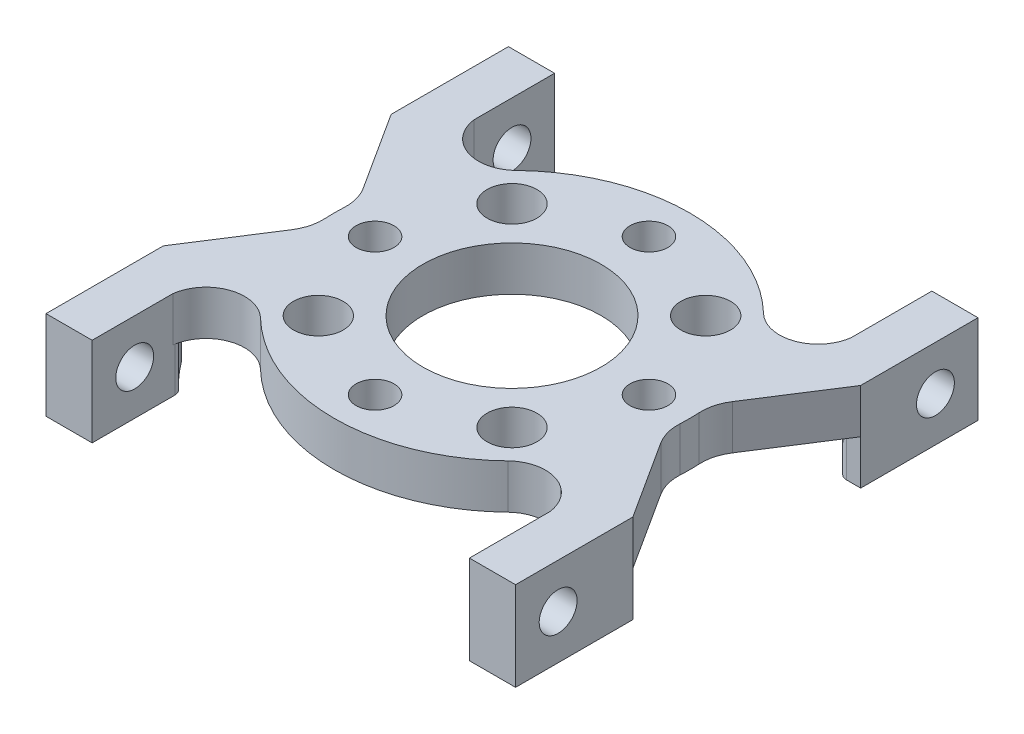
from build123d import *

# Parameters (mm, degrees)
SKETCH1_W                  = 33.528
SKETCH1_H                  = 33.02
BOSS_EXTRUDE1_DEPTH        = 3.175
CUT_EXTRUDE1_DEPTH         = 4.175
SKETCH3_W                  = 3.29438
SKETCH3_H                  = 8.37692
BOSS_EXTRUDE2_DEPTH        = 3.175
CUT_EXTRUDE2_DEPTH         = 7.35
SKETCH5_W                  = 3.29438
SKETCH5_H                  = 8.37692
BOSS_EXTRUDE3_DEPTH        = 3.175
CUT_EXTRUDE3_DEPTH         = 7.35
SKETCH7_W                  = 3.29438
SKETCH7_H                  = 8.37692
BOSS_EXTRUDE4_DEPTH        = 3.175
CUT_EXTRUDE4_DEPTH         = 7.35
SKETCH9_W                  = 3.29438
SKETCH9_H                  = 8.37692
BOSS_EXTRUDE5_DEPTH        = 3.175
CUT_EXTRUDE5_DEPTH         = 3.175
CUT_EXTRUDE6_DEPTH         = 3.175
CUT_EXTRUDE7_DEPTH         = 3.175
CUT_EXTRUDE8_DEPTH         = 3.175
HOLE1_D                    = 12.7254
HOLE1_DEPTH                = 3.175025
M2_5_CLEARANCE_HOLE1_D     = 2.7051
M2_5_CLEARANCE_HOLE1_DEPTH = 3.175025
M3_CLEARANCE_HOLE1_D       = 3.556
M3_CLEARANCE_HOLE1_DEPTH   = 3.175025
M2_5_CLEARANCE_HOLE2_D     = 2.7051
M2_5_CLEARANCE_HOLE2_DEPTH = 3.29438
M2_5_CLEARANCE_HOLE3_D     = 2.7051
M2_5_CLEARANCE_HOLE3_DEPTH = 3.29438
M2_5_CLEARANCE_HOLE4_D     = 2.7051
M2_5_CLEARANCE_HOLE4_DEPTH = 3.29443
FILLET1_R                  = 0.635
FILLET2_R                  = 3.175


with BuildPart() as part:
    # Sketch1 → Boss-Extrude1 (new body)
    with BuildSketch(Plane.XZ):
        Rectangle(SKETCH1_W, SKETCH1_H)
    extrude(amount=-BOSS_EXTRUDE1_DEPTH)

    # Sketch2 → Cut-Extrude1 (cut, through all)
    with BuildSketch(Plane(origin=(0, 3.175, 0), x_dir=(-1, 0, 0), z_dir=(0, 1, 0))):
        with BuildLine():
            Line((-13.46962, 16.51), (-13.46962, 10.753335779))
            ThreePointArc((-13.46962, 10.753335779), (-11.652039651, 8.508623021), (-8.8307675, 9.127296717))
            ThreePointArc((-8.8307675, 9.127296717), (0, 12.7), (8.8307675, 9.127296717))
            ThreePointArc((8.8307675, 9.127296717), (11.652039651, 8.508623021), (13.46962, 10.753335779))
            Line((13.46962, 10.753335779), (13.46962, 16.51))
            Line((13.46962, 16.51), (-13.46962, 16.51))
        make_face()
    extrude(amount=-CUT_EXTRUDE1_DEPTH, mode=Mode.SUBTRACT)

    # Sketch3 → Boss-Extrude2 (add)
    with BuildSketch(Plane.XZ):
        with Locations((-15.11681, 12.32154)):
            Rectangle(SKETCH3_W, SKETCH3_H)
    extrude(amount=BOSS_EXTRUDE2_DEPTH)

    # Sketch4 → Cut-Extrude2 (cut, through all)
    with BuildSketch(Plane(origin=(0, 3.175, 0), x_dir=(-1, 0, 0), z_dir=(0, 1, 0))):
        with BuildLine():
            Line((-16.764, 8.13308), (-16.764, -8.13308))
            Line((-16.764, -8.13308), (-12.593680427, -1.639882101))
            ThreePointArc((-12.593680427, -1.639882101), (-12.7, 0), (-12.593680427, 1.639882101))
            Line((-12.593680427, 1.639882101), (-16.764, 8.13308))
        make_face()
    extrude(amount=-CUT_EXTRUDE2_DEPTH, mode=Mode.SUBTRACT)

    # Sketch5 → Boss-Extrude3 (add)
    with BuildSketch(Plane.XZ):
        with Locations((15.11681, 12.32154)):
            Rectangle(SKETCH5_W, SKETCH5_H)
    extrude(amount=BOSS_EXTRUDE3_DEPTH)

    # Sketch6 → Cut-Extrude3 (cut, through all)
    with BuildSketch(Plane(origin=(0, 3.175, 0), x_dir=(-1, 0, 0), z_dir=(0, 1, 0))):
        with BuildLine():
            Line((13.46962, -16.51), (13.46962, -10.753335779))
            ThreePointArc((13.46962, -10.753335779), (11.652039651, -8.508623021), (8.8307675, -9.127296717))
            ThreePointArc((8.8307675, -9.127296717), (0, -12.7), (-8.8307675, -9.127296717))
            ThreePointArc((-8.8307675, -9.127296717), (-11.652039651, -8.508623021), (-13.46962, -10.753335779))
            Line((-13.46962, -10.753335779), (-13.46962, -16.51))
            Line((-13.46962, -16.51), (13.46962, -16.51))
        make_face()
    extrude(amount=-CUT_EXTRUDE3_DEPTH, mode=Mode.SUBTRACT)

    # Sketch7 → Boss-Extrude4 (add)
    with BuildSketch(Plane.XZ):
        with Locations((15.11681, -12.32154)):
            Rectangle(SKETCH7_W, SKETCH7_H)
    extrude(amount=BOSS_EXTRUDE4_DEPTH)

    # Sketch8 → Cut-Extrude4 (cut, through all)
    with BuildSketch(Plane(origin=(0, 3.175, 0), x_dir=(-1, 0, 0), z_dir=(0, 1, 0))):
        with BuildLine():
            Line((16.764, -8.13308), (16.764, 8.13308))
            Line((16.764, 8.13308), (12.593680427, 1.639882101))
            ThreePointArc((12.593680427, 1.639882101), (12.7, 0), (12.593680427, -1.639882101))
            Line((12.593680427, -1.639882101), (16.764, -8.13308))
        make_face()
    extrude(amount=-CUT_EXTRUDE4_DEPTH, mode=Mode.SUBTRACT)

    # Sketch9 → Boss-Extrude5 (add)
    with BuildSketch(Plane.XZ):
        with Locations((-15.11681, -12.32154)):
            Rectangle(SKETCH9_W, SKETCH9_H)
    extrude(amount=BOSS_EXTRUDE5_DEPTH)

    # Sketch10 → Cut-Extrude5 (cut)
    with BuildSketch(Plane.XZ.offset(3.175)):
        with BuildLine():
            Line((15.422429016, -8.13308), (13.46962, -8.13308))
            Line((13.46962, -8.13308), (13.46962, -10.329337463))
            ThreePointArc((13.46962, -10.329337463), (14.503938678, -9.282703292), (15.422429016, -8.13308))
        make_face()
    extrude(amount=-CUT_EXTRUDE5_DEPTH, mode=Mode.SUBTRACT)

    # Sketch11 → Cut-Extrude6 (cut)
    with BuildSketch(Plane.XZ.offset(3.175)):
        with BuildLine():
            Line((13.46962, 10.329337463), (13.46962, 8.13308))
            Line((13.46962, 8.13308), (15.422429016, 8.13308))
            ThreePointArc((15.422429016, 8.13308), (14.503938678, 9.282703292), (13.46962, 10.329337463))
        make_face()
    extrude(amount=-CUT_EXTRUDE6_DEPTH, mode=Mode.SUBTRACT)

    # Sketch12 → Cut-Extrude7 (cut)
    with BuildSketch(Plane.XZ.offset(3.175)):
        with BuildLine():
            Line((-15.422429016, 8.13308), (-13.46962, 8.13308))
            Line((-13.46962, 8.13308), (-13.46962, 10.329337463))
            ThreePointArc((-13.46962, 10.329337463), (-14.503938678, 9.282703292), (-15.422429016, 8.13308))
        make_face()
    extrude(amount=-CUT_EXTRUDE7_DEPTH, mode=Mode.SUBTRACT)

    # Sketch13 → Cut-Extrude8 (cut)
    with BuildSketch(Plane.XZ.offset(3.175)):
        with BuildLine():
            Line((-13.46962, -10.329337463), (-13.46962, -8.13308))
            Line((-13.46962, -8.13308), (-15.422429016, -8.13308))
            ThreePointArc((-15.422429016, -8.13308), (-14.503938678, -9.282703292), (-13.46962, -10.329337463))
        make_face()
    extrude(amount=-CUT_EXTRUDE8_DEPTH, mode=Mode.SUBTRACT)

    # Hole1
    with Locations(Plane(origin=(0, 0, 0), x_dir=(-1, 0, 0), z_dir=(0, -1, 0))):
        with Locations((0, 0)):
            Hole(HOLE1_D / 2, depth=HOLE1_DEPTH)

    # M2.5 Clearance Hole1
    with Locations(Plane(origin=(0, 0, 0), x_dir=(-1, 0, 0), z_dir=(0, -1, 0))):
        with Locations((0, -9.779), (9.779, 0), (0, 9.779), (-9.779, 0)):
            Hole(M2_5_CLEARANCE_HOLE1_D / 2, depth=M2_5_CLEARANCE_HOLE1_DEPTH)

    # M3 Clearance Hole1
    with Locations(Plane(origin=(0, 0, 0), x_dir=(-1, 0, 0), z_dir=(0, -1, 0))):
        with Locations((6.914797213, -6.914797213), (6.914797213, 6.914797213), (-6.914797213, 6.914797213), (-6.914797213, -6.914797213)):
            Hole(M3_CLEARANCE_HOLE1_D / 2, depth=M3_CLEARANCE_HOLE1_DEPTH)

    # M2.5 Clearance Hole2
    with Locations(Plane(origin=(16.764, 0, 0), x_dir=(0, 0, -1), z_dir=(1, 0, 0))):
        with Locations((13.470384182, 0)):
            Hole(M2_5_CLEARANCE_HOLE2_D / 2, depth=M2_5_CLEARANCE_HOLE2_DEPTH)

    # M2.5 Clearance Hole3
    with Locations(Plane.ZY.offset(-13.46962)):
        with Locations((13.470384182, 0)):
            Hole(M2_5_CLEARANCE_HOLE3_D / 2, depth=M2_5_CLEARANCE_HOLE3_DEPTH)

    # M2.5 Clearance Hole4
    with Locations(Plane(origin=(-13.46962, 0, 0), x_dir=(0, 0, -1), z_dir=(1, 0, 0))):
        with Locations((-13.470384182, 0), (13.470384182, 0)):
            Hole(M2_5_CLEARANCE_HOLE4_D / 2, depth=M2_5_CLEARANCE_HOLE4_DEPTH)

    # Fillet1
    fillet1_edges = [part.edges().sort_by_distance(p)[0] for p in [
        (-13.46962, -1.5875, -10.329337463),
        (-15.422429016, -1.5875, 8.13308),
        (15.422429016, -1.5875, -8.13308),
        (15.422429016, -1.5875, 8.13308),
        (13.46962, -1.5875, -10.329337463),
        (-13.46962, -1.5875, 10.329337463),
        (-15.422429016, -1.5875, -8.13308),
        (13.46962, -1.5875, 10.329337463),
    ]]
    fillet(fillet1_edges, radius=FILLET1_R)

    # Fillet2
    fillet2_edges = [part.edges().sort_by_distance(p)[0] for p in [
        (-12.593680427, 1.5875, -1.639882101),
        (12.593680427, 1.5875, -1.639882101),
        (-12.593680427, 1.5875, 1.639882101),
        (12.593680427, 1.5875, 1.639882101),
    ]]
    fillet(fillet2_edges, radius=FILLET2_R)


solid = part.part
